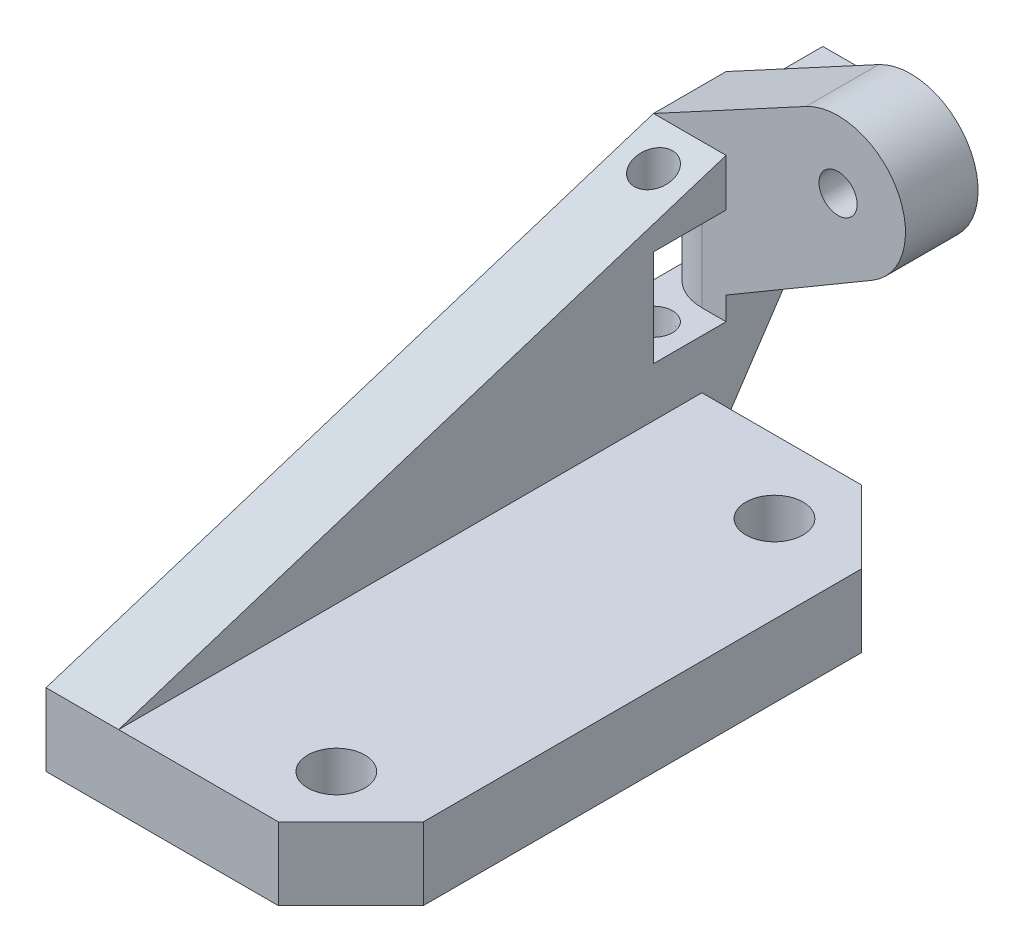
from build123d import *

# Parameters (mm, degrees)
SKETCH1_W                    = 12.192
SKETCH1_H                    = 30.62
SKETCH1_R                    = 1.5
BOSS_EXTRUDE1_DEPTH          = 3.81
BOSS_EXTRUDE2_DEPTH          = 3.81
SKETCH3_W                    = 1.778
SKETCH3_H                    = 1.778
BOSS_EXTRUDE3_DEPTH          = 5.08
SKETCH4_R                    = 1
BOSS_EXTRUDE4_DEPTH          = 3.81
CUT_EXTRUDE1_REACH           = 18.002
SKETCH5_W                    = 3.81
SKETCH5_H                    = 5.08
SKETCH6_R                    = 1
CUT_EXTRUDE2_DEPTH           = 13.310347601
CUT_EXTRUDE2_OTHER_WAY_DEPTH = 5.08
CUT_EXTRUDE2_OTHER_WAY_TAPER = 5
CHAMFER1_SIZE                = 0.762
FILLET1_R                    = 2.54
CHAMFER2_SIZE                = 3.81
FILLET2_R                    = 0.762


with BuildPart() as part:
    # Sketch1 → Boss-Extrude1 (new body)
    with BuildSketch(Plane(origin=(0, 0, 0), x_dir=(1, 0, 0), z_dir=(0, 1, 0))):
        with Locations((6.096, 15.31)):
            Rectangle(SKETCH1_W, SKETCH1_H)
        with Locations((7.62, 26.81)):
            Circle(SKETCH1_R, mode=Mode.SUBTRACT)
        with Locations((7.62, 3.81)):
            Circle(SKETCH1_R, mode=Mode.SUBTRACT)
    extrude(amount=BOSS_EXTRUDE1_DEPTH)

    # Sketch2 → Boss-Extrude2 (add)
    with BuildSketch(Plane.ZY):
        Polygon((0, 3.81), (0, 0), (-30.62, 0), (-35.7, 7.62), (-35.7, 13.97), (-31.89, 13.97), align=None)
    extrude(amount=BOSS_EXTRUDE2_DEPTH)

    # Sketch3 → Boss-Extrude3 (add)
    with BuildSketch(Plane(origin=(0, 0, -35.7), x_dir=(-1, 0, 0), z_dir=(0, 0, -1))):
        with Locations((2.921, 8.509)):
            Rectangle(SKETCH3_W, SKETCH3_H)
        with Locations((2.921, 11.684)):
            Rectangle(SKETCH3_W, SKETCH3_H)
    extrude(amount=BOSS_EXTRUDE3_DEPTH)

    # Sketch4 → Boss-Extrude4 (add)
    with BuildSketch(Plane(origin=(0, 0, -35.7), x_dir=(-1, 0, 0), z_dir=(0, 0, -1))):
        with BuildLine():
            Line((0, 7.62), (-7.670279519, 12.123848354))
            ThreePointArc((-7.670279519, 12.123848354), (-8.962218829, 16.913759957), (-4.196321779, 18.2916517))
            Line((-4.196321779, 18.2916517), (3.81, 13.97))
            Line((3.81, 13.97), (0, 13.97))
            Line((0, 13.97), (0, 7.62))
        make_face()
        with Locations((-5.877818102, 15.1765)):
            Circle(SKETCH4_R, mode=Mode.SUBTRACT)
    extrude(amount=-BOSS_EXTRUDE4_DEPTH)

    # Sketch5 → Cut-Extrude1 (cut, up to next)
    with BuildSketch(Plane.ZY.offset(3.81), mode=Mode.PRIVATE) as cut_extrude1_sk1:
        with Locations((-29.985, 8.946152399)):
            Rectangle(SKETCH5_W, SKETCH5_H)
    cut_extrude1_tool1 = extrude(cut_extrude1_sk1.sketch, amount=-CUT_EXTRUDE1_REACH, mode=Mode.PRIVATE) & part.part
    add(cut_extrude1_tool1.solids().sort_by_distance((-3.81, 8.946152, -29.985))[0], mode=Mode.SUBTRACT)

    # Sketch6 → Cut-Extrude2 (cut)
    with BuildSketch(Plane(origin=(0, 6.406152399, 0), x_dir=(1, 0, 0), z_dir=(0, 1, 0))):
        with Locations((-1.905, 29.985)):
            Circle(SKETCH6_R)
    extrude(amount=CUT_EXTRUDE2_DEPTH, mode=Mode.SUBTRACT)

    # Sketch6 → Cut-Extrude2 other way (cut)
    with BuildSketch(Plane(origin=(0, 6.406152399, 0), x_dir=(1, 0, 0), z_dir=(0, 1, 0))):
        with Locations((-1.905, 29.985)):
            Circle(SKETCH6_R)
    extrude(amount=-CUT_EXTRUDE2_OTHER_WAY_DEPTH, taper=CUT_EXTRUDE2_OTHER_WAY_TAPER, mode=Mode.SUBTRACT)

    # Chamfer1
    chamfer1_edges = [part.edges().sort_by_distance(p)[0] for p in [
        (-3.81, 9.398, -38.24),
        (-2.032, 9.398, -38.24),
        (-2.032, 10.795, -38.24),
    ]]
    chamfer(chamfer1_edges, length=CHAMFER1_SIZE)

    # Fillet1
    fillet1_edges = [part.edges().sort_by_distance(p)[0] for p in [
        (-3.81, 8.946152399, -31.89),
    ]]
    fillet(fillet1_edges, radius=FILLET1_R)

    # Chamfer2
    chamfer2_edges = [part.edges().sort_by_distance(p)[0] for p in [
        (12.192, 1.905, -30.62),
        (12.192, 1.905, 0),
    ]]
    chamfer(chamfer2_edges, length=CHAMFER2_SIZE)

    # Fillet2
    fillet2_edges = [part.edges().sort_by_distance(p)[0] for p in [
        (-3.81, 10.0965, -35.7),
    ]]
    fillet(fillet2_edges, radius=FILLET2_R)


solid = part.part
